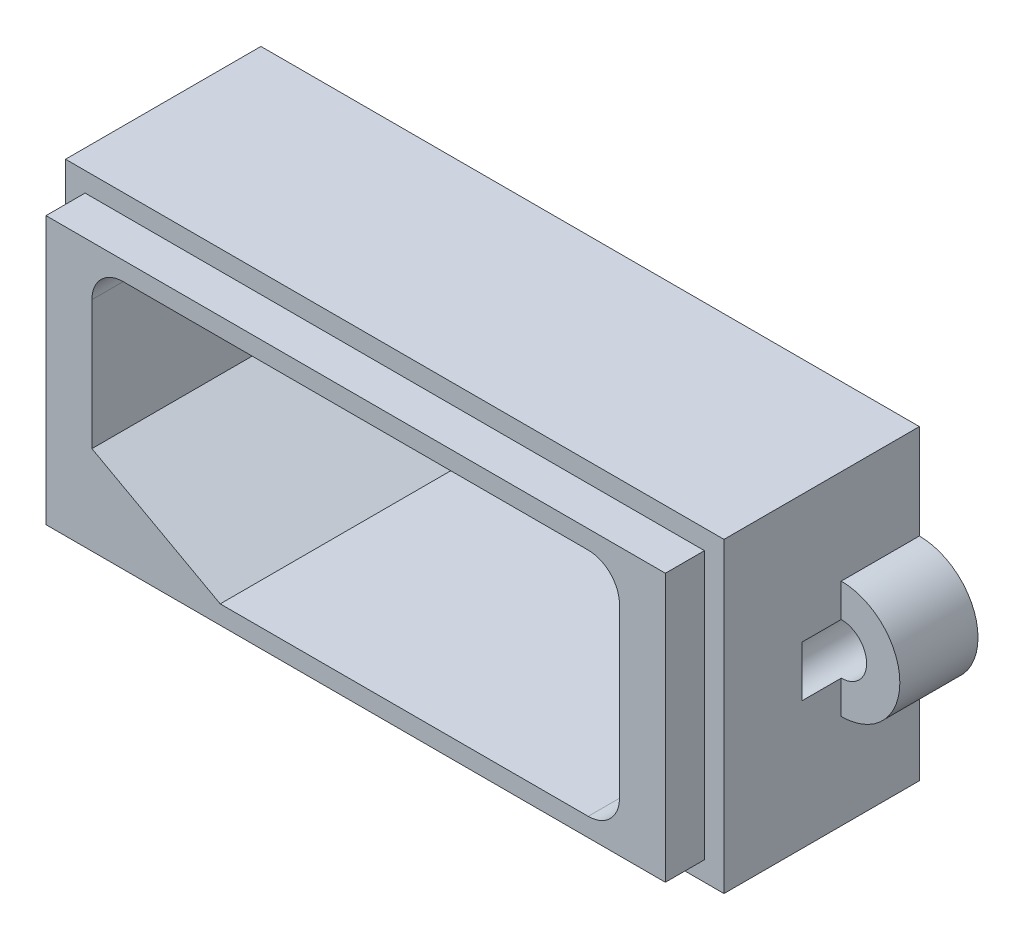
from build123d import *

# Parameters (mm, degrees)
CROQUIS1_W              = 33.7
CROQUIS1_H              = 15.7
SALIENTE_EXTRUIR1_DEPTH = 5
CROQUIS2_W              = 31.7
CROQUIS2_H              = 13.7
SALIENTE_EXTRUIR2_DEPTH = 2
CORTAR_EXTRUIR1_DEPTH   = 10
CROQUIS4_W              = 33.7
CROQUIS4_H              = 15.7
SALIENTE_EXTRUIR3_DEPTH = 5
CROQUIS6_R              = 3
SALIENTE_EXTRUIR5_DEPTH = 4
SALIENTE_EXTRUIR6_DEPTH = 12
CROQUIS8_R              = 1.3
CORTAR_EXTRUIR2_DEPTH   = 6


with BuildPart() as part:
    # Croquis1 → Saliente-Extruir1 (new body)
    with BuildSketch(Plane(origin=(0, 0, 178), x_dir=(-1, 0, 0), z_dir=(0, 0, -1))):
        with Locations((13.350397628, -3.774933729)):
            Rectangle(CROQUIS1_W, CROQUIS1_H)
    extrude(amount=SALIENTE_EXTRUIR1_DEPTH)

    # Croquis2 → Saliente-Extruir2 (add)
    with BuildSketch(Plane.XY.offset(178)):
        with Locations((-13.350397628, -3.774933729)):
            Rectangle(CROQUIS2_W, CROQUIS2_H)
    extrude(amount=SALIENTE_EXTRUIR2_DEPTH)

    # Croquis3 → Cortar-Extruir1 (cut)
    with BuildSketch(Plane.XY.offset(180)):
        with BuildLine():
            Line((-25.250397628, 2.125066271), (-1.450397628, 2.125066271))
            ThreePointArc((-1.450397628, 2.125066271), (-0.319026778, 1.656437121), (0.149602372, 0.525066271))
            Line((0.149602372, 0.525066271), (0.149602372, -8.074933729))
            ThreePointArc((0.149602372, -8.074933729), (-0.319026778, -9.206304579), (-1.450397628, -9.674933729))
            Line((-1.450397628, -9.674933729), (-25.250397628, -9.674933729))
            ThreePointArc((-25.250397628, -9.674933729), (-26.381768478, -9.206304579), (-26.850397628, -8.074933729))
            Line((-26.850397628, -8.074933729), (-26.850397628, 0.525066271))
            ThreePointArc((-26.850397628, 0.525066271), (-26.381768478, 1.656437121), (-25.250397628, 2.125066271))
        make_face()
    extrude(amount=-CORTAR_EXTRUIR1_DEPTH, mode=Mode.SUBTRACT)

    # Croquis4 → Saliente-Extruir3 (add)
    with BuildSketch(Plane(origin=(0, 0, 173), x_dir=(-1, 0, 0), z_dir=(0, 0, -1))):
        with Locations((13.350397628, -3.774933729)):
            Rectangle(CROQUIS4_W, CROQUIS4_H)
        with BuildLine():
            Line((1.450397628, -9.674933729), (25.250397628, -9.674933729))
            ThreePointArc((25.250397628, -9.674933729), (26.381768478, -9.206304579), (26.850397628, -8.074933729))
            Line((26.850397628, -8.074933729), (26.850397628, 0.525066271))
            ThreePointArc((26.850397628, 0.525066271), (26.381768478, 1.656437121), (25.250397628, 2.125066271))
            Line((25.250397628, 2.125066271), (1.450397628, 2.125066271))
            ThreePointArc((1.450397628, 2.125066271), (0.319026778, 1.656437121), (-0.149602372, 0.525066271))
            Line((-0.149602372, 0.525066271), (-0.149602372, -8.074933729))
            ThreePointArc((-0.149602372, -8.074933729), (0.319026778, -9.206304579), (1.450397628, -9.674933729))
        make_face(mode=Mode.SUBTRACT)
    extrude(amount=SALIENTE_EXTRUIR3_DEPTH)

    # Croquis6 → Saliente-Extruir5 (add)
    with BuildSketch(Plane(origin=(0, 0, 168), x_dir=(-1, 0, 0), z_dir=(0, 0, -1))):
        with Locations((-3.499602372, -3.774933729)):
            Circle(CROQUIS6_R)
        with Locations((30.200397628, -3.774933729)):
            Circle(CROQUIS6_R)
    extrude(amount=-SALIENTE_EXTRUIR5_DEPTH)

    # Croquis7 → Saliente-Extruir6 (add)
    with BuildSketch(Plane(origin=(0, 0, 168), x_dir=(-1, 0, 0), z_dir=(0, 0, -1))):
        with BuildLine():
            Line((20.284128272, -9.674933729), (26.850397628, -6.079245942))
            Line((26.850397628, -6.079245942), (26.850397628, -8.074933729))
            ThreePointArc((26.850397628, -8.074933729), (26.381768478, -9.206304579), (25.250397628, -9.674933729))
            Line((25.250397628, -9.674933729), (20.284128272, -9.674933729))
        make_face()
    extrude(amount=-SALIENTE_EXTRUIR6_DEPTH)

    # Croquis8 → Cortar-Extruir2 (cut)
    with BuildSketch(Plane(origin=(0, 0, 168), x_dir=(-1, 0, 0), z_dir=(0, 0, -1))):
        with Locations((-3.499602372, -3.774933729)):
            Circle(CROQUIS8_R)
        with Locations((30.200397628, -3.774933729)):
            Circle(CROQUIS8_R)
    extrude(amount=-CORTAR_EXTRUIR2_DEPTH, mode=Mode.SUBTRACT)


solid = part.part
